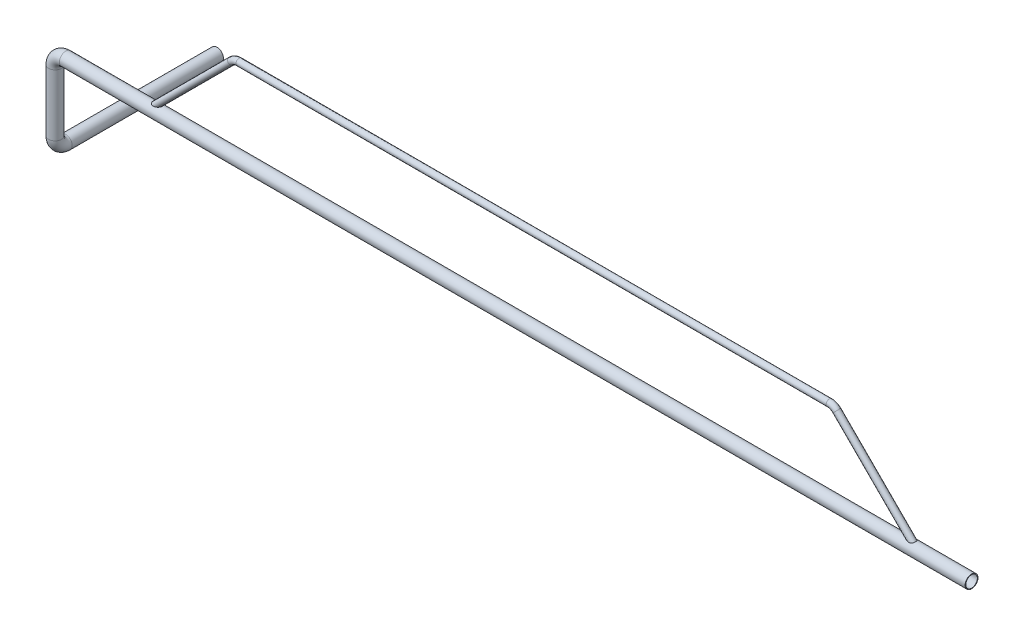
from build123d import *

# Parameters (mm, degrees)
SWEEP_THIN1_PROFILE_R   = 30
SWEEP_THIN1_PROFILE_R_2 = 27
SWEEP_THIN2_PROFILE_R   = 15
SWEEP_THIN2_PROFILE_R_2 = 12


with BuildPart() as part:
    # Sweep-Thin1: sweep along a curve in space
    with BuildLine() as sweep_thin1_path:
        Line((-24893.15764982, -8333.514738936, 39491.70019632), (-29116.65764982, -8333.514738936, 39491.70019632))
        ThreePointArc((-29166.65764982, -8383.514738936, 39491.70019632), (-29152.012988879, -8348.159399877, 39491.70019632), (-29116.65764982, -8333.514738936, 39491.70019632))
        Line((-29166.65764982, -8383.514738936, 39491.70019632), (-29166.65764982, -8670.228633413, 39491.70019632))
        ThreePointArc((-29166.65764982, -8670.228633413, 39491.70019632), (-29166.65764982, -8705.583972472, 39477.055535379), (-29166.65764982, -8720.228633413, 39441.70019632))
        Line((-29166.65764982, -8720.228633413, 39441.70019632), (-29166.65764982, -8720.228633413, 38736.700196057))
    # Sweep-Thin1 profile (on start of the path) → Sweep-Thin1 (sweep)
    with BuildSketch(Plane(origin=(-24893.15764982, -8333.514738936, 39491.70019632), x_dir=(0, 0, -1), z_dir=(-1, 0, 0))):
        Circle(SWEEP_THIN1_PROFILE_R)
        Circle(SWEEP_THIN1_PROFILE_R_2, mode=Mode.SUBTRACT)
    sweep(path=sweep_thin1_path.line)

    # Sweep-Thin2: sweep along a curve in space
    with BuildLine() as sweep_thin2_path:
        Line((-25145.086331851, -8333.514738936, 39491.70019632), (-25521.014275827, -7957.586794961, 39491.70019632))
        ThreePointArc((-25521.014275827, -7957.586794961, 39491.70019632), (-25537.235443268, -7946.748157394, 39491.70019632), (-25556.369614886, -7942.94213402, 39491.70019632))
        Line((-25556.369614886, -7942.94213402, 39491.70019632), (-28308.534256611, -7942.94213402, 39491.70019632))
        ThreePointArc((-28308.534256611, -7942.94213402, 39491.70019632), (-28327.668428229, -7946.748157394, 39491.70019632), (-28343.88959567, -7957.586794961, 39491.70019632))
        Line((-28343.88959567, -7957.586794961, 39491.70019632), (-28719.817539646, -8333.514738936, 39491.70019632))
    # Sweep-Thin2 profile (on start of the path) → Sweep-Thin2 (sweep)
    with BuildSketch(Plane(origin=(-25145.086331851, -8333.514738936, 39491.70019632), x_dir=(-0.707106781186539, -0.7071067811865561, 0), z_dir=(-0.7071067811865561, 0.707106781186539, 0))):
        Circle(SWEEP_THIN2_PROFILE_R)
        Circle(SWEEP_THIN2_PROFILE_R_2, mode=Mode.SUBTRACT)
    sweep(path=sweep_thin2_path.line)


solid = part.part
